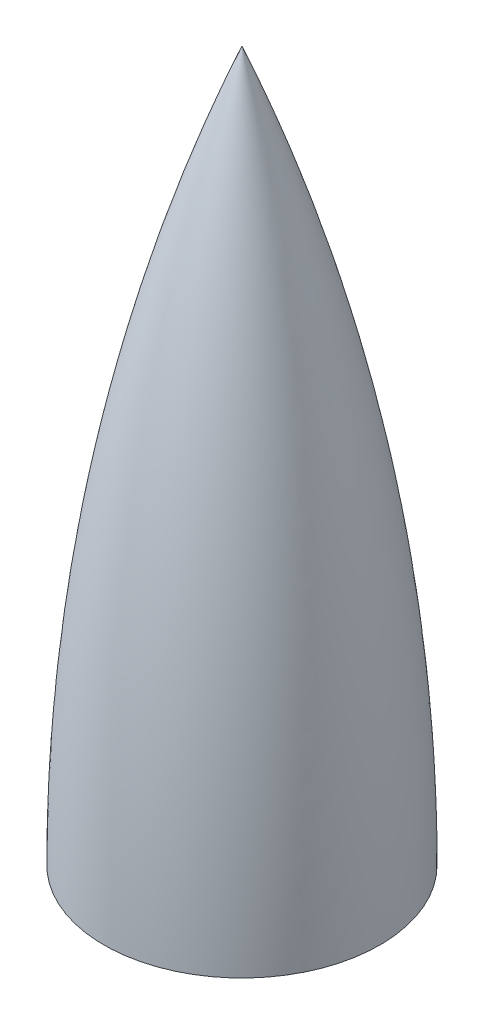
from build123d import *


with BuildPart() as part:
    # Sketch1 → Revolve2 (revolve)
    with BuildSketch(Plane.XY):
        with BuildLine():
            Line((0, 0), (3500, 0))
            ThreePointArc((3500, 0), (2616.895242931, 9168.562963903), (0, 18000))
            Line((0, 18000), (0, 0))
        make_face()
    revolve(axis=Axis((0, 0, 0), (0, 1, 0)))


solid = part.part
